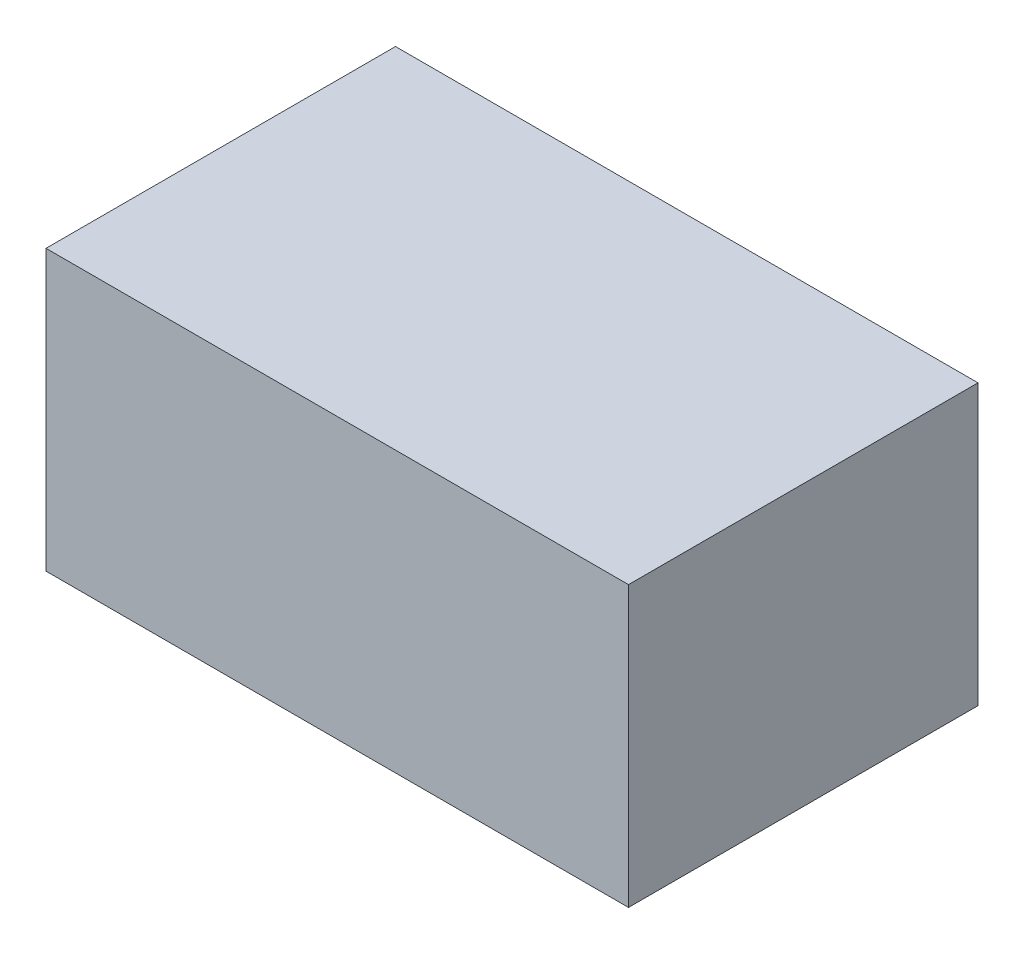
from build123d import *

# Parameters (mm, degrees)
SKETCH1_W           = 7.5
SKETCH1_H           = 4.5
BOSS_EXTRUDE1_DEPTH = 3.6


with BuildPart() as part:
    # Sketch1 → Boss-Extrude1 (new body)
    with BuildSketch(Plane(origin=(0, 0, 0), x_dir=(1, 0, 0), z_dir=(0, 1, 0))):
        Rectangle(SKETCH1_W, SKETCH1_H)
    extrude(amount=BOSS_EXTRUDE1_DEPTH)


solid = part.part
